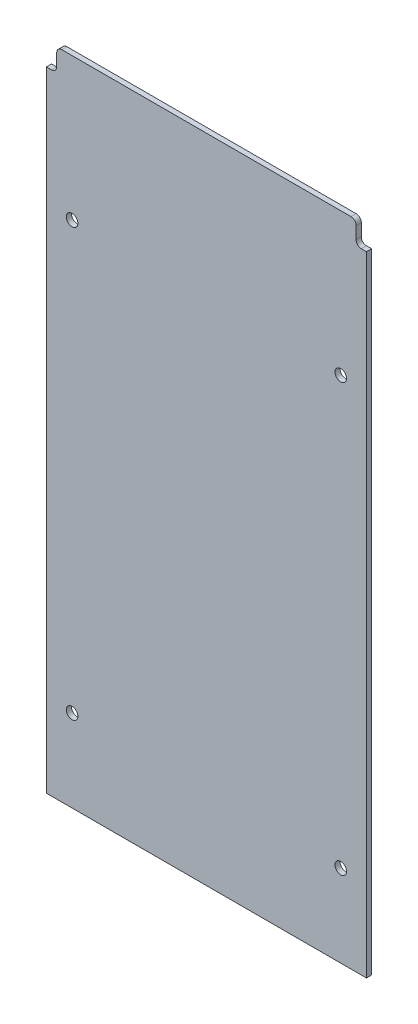
from build123d import *

# Parameters (mm, degrees)
SKETCH1_W                   = 197.5866
SKETCH1_H                   = 402.272499995
BOSS_EXTRUDE1_DEPTH         = 3.175
SKETCH3_W                   = 6.35
SKETCH3_H                   = 13.97
CUT_EXTRUDE1_DEPTH          = 4.175
FILLET1_R                   = 3.175
F_1_4_CLEARANCE_HOLE1_D     = 7.14248
F_1_4_CLEARANCE_HOLE1_DEPTH = 3.175


with BuildPart() as part:
    # Sketch1 → Boss-Extrude1 (new body)
    with BuildSketch(Plane.XY):
        with Locations((182.40375, -160.813750003)):
            Rectangle(SKETCH1_W, SKETCH1_H)
    extrude(amount=BOSS_EXTRUDE1_DEPTH)

    # Sketch3 → Cut-Extrude1 (cut, through all)
    with BuildSketch(Plane.XY.offset(3.175)):
        with Locations((86.78545, 33.337499995)):
            Rectangle(SKETCH3_W, SKETCH3_H)
        with Locations((278.02205, 33.337499995)):
            Rectangle(SKETCH3_W, SKETCH3_H)
    extrude(amount=-CUT_EXTRUDE1_DEPTH, mode=Mode.SUBTRACT)

    # Fillet1
    fillet1_edges = [part.edges().sort_by_distance(p)[0] for p in [
        (89.96045, 40.322499995, 1.5875),
        (89.96045, 26.352499995, 1.5875),
        (274.84705, 26.352499995, 1.5875),
        (274.84705, 40.322499995, 1.5875),
    ]]
    fillet(fillet1_edges, radius=FILLET1_R)

    # 1/4 Clearance Hole1
    with Locations(Plane.XY.offset(3.175)):
        with Locations((99.485400307, -47.621943918), (265.32205, -47.625), (265.32205, -311.15), (99.485499692, -311.146943918)):
            Hole(F_1_4_CLEARANCE_HOLE1_D / 2, depth=F_1_4_CLEARANCE_HOLE1_DEPTH)


solid = part.part
